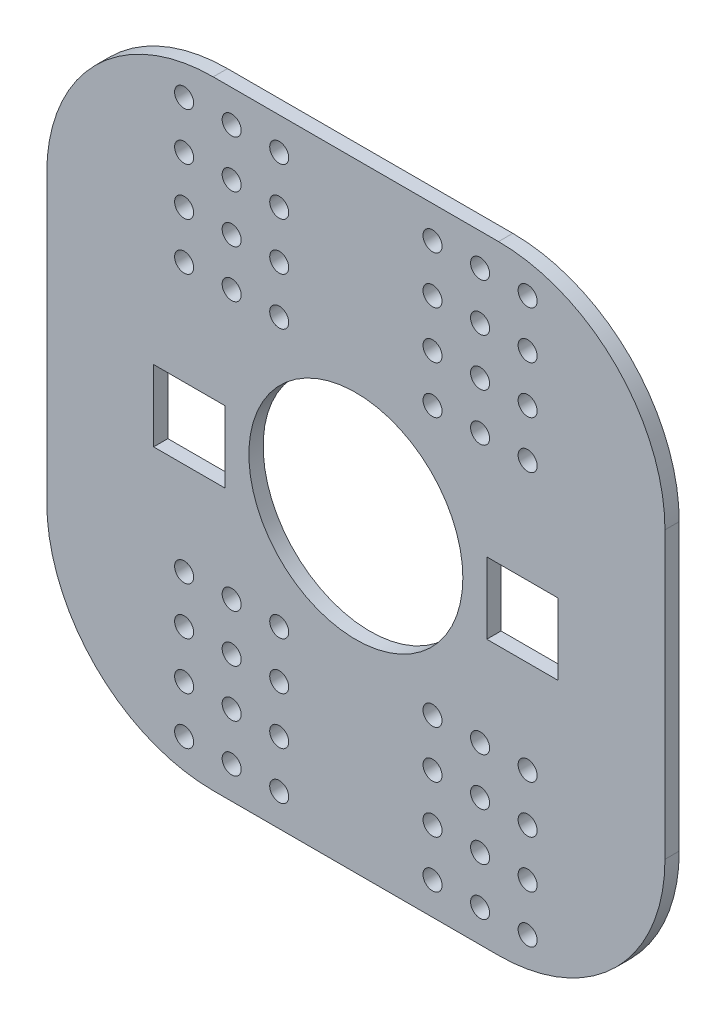
from build123d import *

# Parameters (mm, degrees)
SKETCH_1_W          = 130
SKETCH_1_H          = 130
SKETCH_1_R          = 22.5
EXTRUDE_1_DEPTH     = 3
FILLET_1_R          = 35
SKETCH_5_R          = 2
SKETCH_5_W          = 15
SKETCH_5_H          = 15
CUT_EXTRUDE_2_DEPTH = 13


with BuildPart() as part:
    # 草图1 → 凸台-拉伸1 (new body)
    with BuildSketch(Plane.XY):
        Rectangle(SKETCH_1_W, SKETCH_1_H)
        Circle(SKETCH_1_R, mode=Mode.SUBTRACT)
    extrude(amount=-EXTRUDE_1_DEPTH)

    # 圆角1
    fillet_1_edges = [part.edges().sort_by_distance(p)[0] for p in [
        (65, -65, -1.5),
        (-65, -65, -1.5),
        (-65, 65, -1.5),
        (65, 65, -1.5),
    ]]
    fillet(fillet_1_edges, radius=FILLET_1_R)

    # 草图5 → 切除-拉伸2 (cut)
    with BuildSketch(Plane(origin=(0, 0, -3), x_dir=(-1, 0, 0), z_dir=(0, 0, -1))):
        with Locations((36.119111303, 58.196758832)):
            Circle(SKETCH_5_R)
        with Locations((36.119111303, 48.196758832)):
            Circle(SKETCH_5_R)
        with Locations((36.119111303, 38.196758832)):
            Circle(SKETCH_5_R)
        with Locations((-36.119111303, -58.196758832)):
            Circle(SKETCH_5_R)
        with Locations((16.119111303, 48.196758832)):
            Circle(SKETCH_5_R)
        with Locations((16.119111303, 38.196758832)):
            Circle(SKETCH_5_R)
        with Locations((16.119111303, 28.196758832)):
            Circle(SKETCH_5_R)
        with Locations((26.119111303, 58.196758832)):
            Circle(SKETCH_5_R)
        with Locations((16.119111303, -48.196758832)):
            Circle(SKETCH_5_R)
        with Locations((26.119111303, -28.196758832)):
            Circle(SKETCH_5_R)
        with Locations((36.119111303, 28.196758832)):
            Circle(SKETCH_5_R)
        with Locations((26.119111303, 48.196758832)):
            Circle(SKETCH_5_R)
        with Locations((26.119111303, 38.196758832)):
            Circle(SKETCH_5_R)
        with Locations((26.119111303, 28.196758832)):
            Circle(SKETCH_5_R)
        with Locations((16.119111303, 58.196758832)):
            Circle(SKETCH_5_R)
        with Locations((16.119111303, -58.196758832)):
            Circle(SKETCH_5_R)
        with Locations((26.119111303, -58.196758832)):
            Circle(SKETCH_5_R)
        with Locations((16.119111303, -28.196758832)):
            Circle(SKETCH_5_R)
        with Locations((16.119111303, -38.196758832)):
            Circle(SKETCH_5_R)
        with Locations((36.119111303, -38.196758832)):
            Circle(SKETCH_5_R)
        with Locations((36.119111303, -48.196758832)):
            Circle(SKETCH_5_R)
        with Locations((36.119111303, -58.196758832)):
            Circle(SKETCH_5_R)
        with Locations((-36.119111303, -48.196758832)):
            Circle(SKETCH_5_R)
        with Locations((-36.119111303, -38.196758832)):
            Circle(SKETCH_5_R)
        with Locations((-16.119111303, -38.196758832)):
            Circle(SKETCH_5_R)
        with Locations((-16.119111303, -28.196758832)):
            Circle(SKETCH_5_R)
        with Locations((-26.119111303, -58.196758832)):
            Circle(SKETCH_5_R)
        with Locations((26.119111303, -38.196758832)):
            Circle(SKETCH_5_R)
        with Locations((26.119111303, -48.196758832)):
            Circle(SKETCH_5_R)
        with Locations((36.119111303, -28.196758832)):
            Circle(SKETCH_5_R)
        with Locations((-36.119111303, -28.196758832)):
            Circle(SKETCH_5_R)
        with Locations((-26.119111303, -48.196758832)):
            Circle(SKETCH_5_R)
        with Locations((-26.119111303, -38.196758832)):
            Circle(SKETCH_5_R)
        with Locations((-26.119111303, -28.196758832)):
            Circle(SKETCH_5_R)
        with Locations((-16.119111303, -48.196758832)):
            Circle(SKETCH_5_R)
        with Locations((-16.119111303, 28.196758832)):
            Circle(SKETCH_5_R)
        with Locations((-16.119111303, 38.196758832)):
            Circle(SKETCH_5_R)
        with Locations((-16.119111303, 48.196758832)):
            Circle(SKETCH_5_R)
        with Locations((-26.119111303, 28.196758832)):
            Circle(SKETCH_5_R)
        with Locations((-26.119111303, 38.196758832)):
            Circle(SKETCH_5_R)
        with Locations((-36.119111303, 38.196758832)):
            Circle(SKETCH_5_R)
        with Locations((-36.119111303, 48.196758832)):
            Circle(SKETCH_5_R)
        with Locations((-36.119111303, 58.196758832)):
            Circle(SKETCH_5_R)
        with Locations((-16.119111303, -58.196758832)):
            Circle(SKETCH_5_R)
        with Locations((-16.119111303, 58.196758832)):
            Circle(SKETCH_5_R)
        with Locations((-26.119111303, 58.196758832)):
            Circle(SKETCH_5_R)
        with Locations((-26.119111303, 48.196758832)):
            Circle(SKETCH_5_R)
        with Locations((-36.119111303, 28.196758832)):
            Circle(SKETCH_5_R)
        with Locations((35.031984266, -1.155156202)):
            Rectangle(SKETCH_5_W, SKETCH_5_H)
        with Locations((-35.031984266, -1.155156202)):
            Rectangle(SKETCH_5_W, SKETCH_5_H)
    extrude(amount=-CUT_EXTRUDE_2_DEPTH, mode=Mode.SUBTRACT)


solid = part.part
